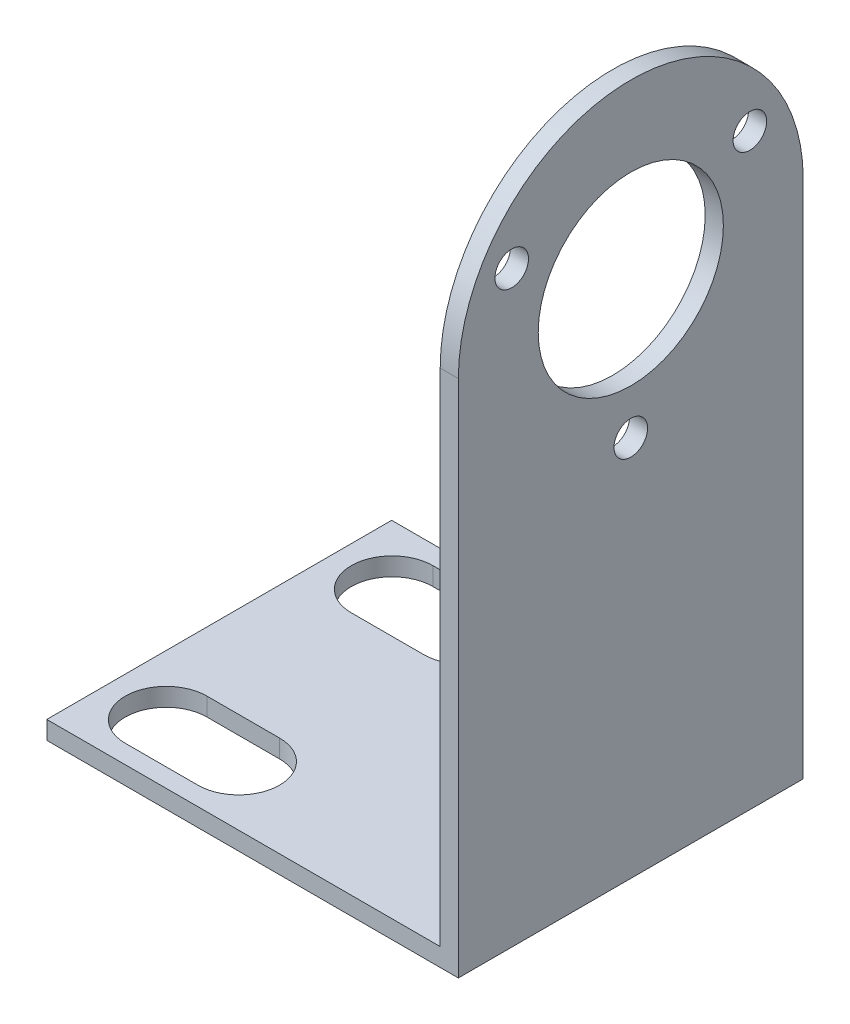
from build123d import *

# Parameters (mm, degrees)
SKETCH1_W           = 45.35
SKETCH1_H           = 38
BOSS_EXTRUDE1_DEPTH = 2
SKETCH2_W           = 2
SKETCH2_H           = 38
BOSS_EXTRUDE2_DEPTH = 74.25
SKETCH3_R           = 10.2
SKETCH3_R_2         = 1.85
CUT_EXTRUDE1_DEPTH  = 50
CUT_EXTRUDE2_DEPTH  = 46.35
CUT_EXTRUDE3_DEPTH  = 3


with BuildPart() as part:
    # Sketch1 → Boss-Extrude1 (new body)
    with BuildSketch(Plane(origin=(0, 0, 0), x_dir=(1, 0, 0), z_dir=(0, 1, 0))):
        with Locations((-22.675, 2.976284585)):
            Rectangle(SKETCH1_W, SKETCH1_H)
    extrude(amount=BOSS_EXTRUDE1_DEPTH)

    # Sketch2 → Boss-Extrude2 (add)
    with BuildSketch(Plane(origin=(0, 2, 0), x_dir=(1, 0, 0), z_dir=(0, 1, 0))):
        with Locations((-1, 2.976284585)):
            Rectangle(SKETCH2_W, SKETCH2_H)
    extrude(amount=BOSS_EXTRUDE2_DEPTH)

    # Sketch3 → Cut-Extrude1 (cut)
    with BuildSketch(Plane.ZY.offset(2)):
        with Locations((-2.976284585, 57.2)):
            Circle(SKETCH3_R)
        with Locations((-16.096569452, 64.775)):
            Circle(SKETCH3_R_2)
        with Locations((10.144000282, 64.775)):
            Circle(SKETCH3_R_2)
        with Locations((-2.976284585, 42.05)):
            Circle(SKETCH3_R_2)
    extrude(amount=-CUT_EXTRUDE1_DEPTH, mode=Mode.SUBTRACT)

    # Sketch14 → Cut-Extrude2 (cut, through all)
    with BuildSketch(Plane(origin=(0, 0, 0), x_dir=(0, 0, -1), z_dir=(1, 0, 0))):
        with BuildLine():
            Line((-16.023715415, 57.2), (-16.023715415, 90.282409195))
            Line((-16.023715415, 90.282409195), (21.976284585, 90.282409195))
            Line((21.976284585, 90.282409195), (21.976284585, 57.2))
            ThreePointArc((21.976284585, 57.2), (2.976284585, 76.2), (-16.023715415, 57.2))
        make_face()
    extrude(amount=-CUT_EXTRUDE2_DEPTH, mode=Mode.SUBTRACT)

    # Sketch15 → Cut-Extrude3 (cut, through all)
    with BuildSketch(Plane(origin=(0, 2, 0), x_dir=(1, 0, 0), z_dir=(0, 1, 0))):
        with BuildLine():
            Line((-30.75, -13.973715415), (-38.75, -13.973715415))
            ThreePointArc((-38.75, -13.973715415), (-43.25, -9.473715415), (-38.75, -4.973715415))
            Line((-38.75, -4.973715415), (-30.75, -4.973715415))
            ThreePointArc((-30.75, -4.973715415), (-26.25, -9.473715415), (-30.75, -13.973715415))
        make_face()
        with BuildLine():
            Line((-30.75, 19.926284585), (-38.75, 19.926284585))
            ThreePointArc((-38.75, 19.926284585), (-43.25, 15.426284585), (-38.75, 10.926284585))
            Line((-38.75, 10.926284585), (-30.75, 10.926284585))
            ThreePointArc((-30.75, 10.926284585), (-26.25, 15.426284585), (-30.75, 19.926284585))
        make_face()
    extrude(amount=-CUT_EXTRUDE3_DEPTH, mode=Mode.SUBTRACT)


solid = part.part
